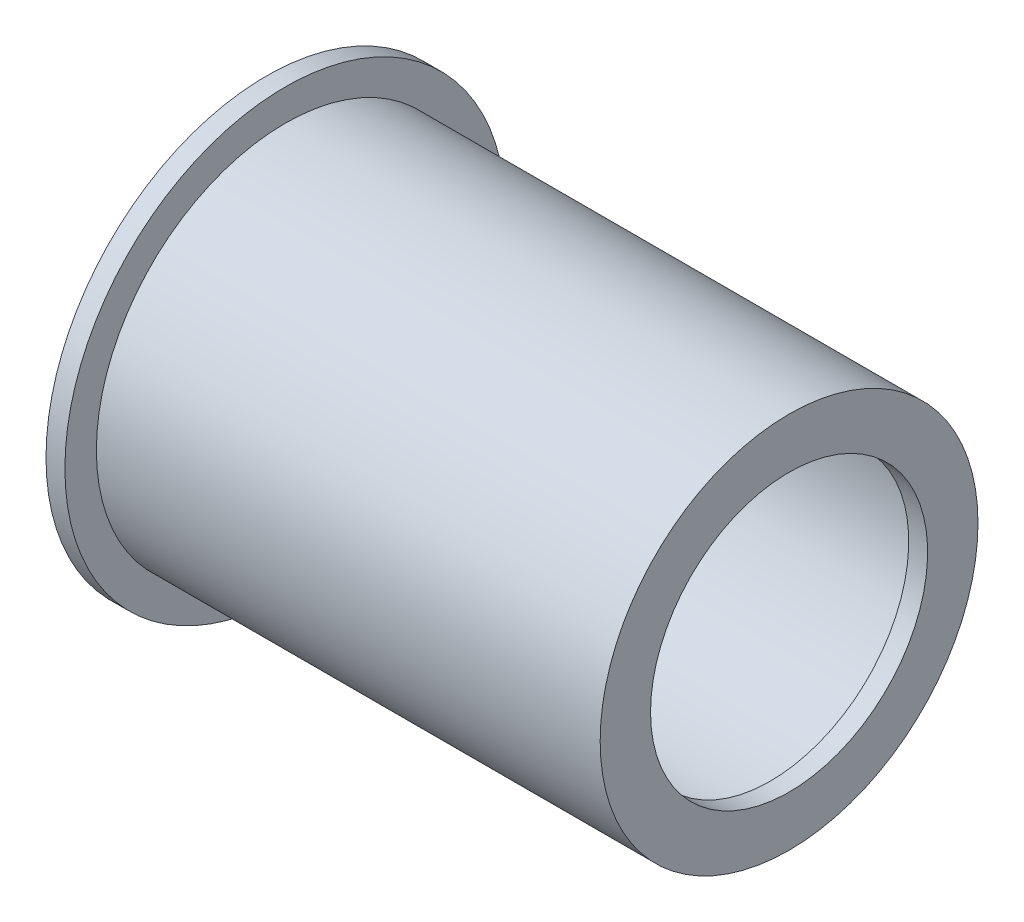
from build123d import *

# Parameters (mm, degrees)
SKETCH2_R           = 27
BOSS_EXTRUDE1_DEPTH = 3


with BuildPart() as part:
    # Sketch1 → Revolve-Thin1 (revolve)
    with BuildSketch(Plane.XY):
        Polygon((8.218422341, 35), (8.218422341, 27), (88.218422341, 27), (88.218422341, 22), (91.218422341, 22), (91.218422341, 30), (11.218422341, 30), (11.218422341, 35), align=None)
    revolve(axis=Axis((0, 0, 0), (1, 0, 0)))

    # Sketch2 → Boss-Extrude1 (add)
    with BuildSketch(Plane.ZY.offset(-8.218422341)):
        Circle(SKETCH2_R)
    extrude(amount=-BOSS_EXTRUDE1_DEPTH)


solid = part.part
